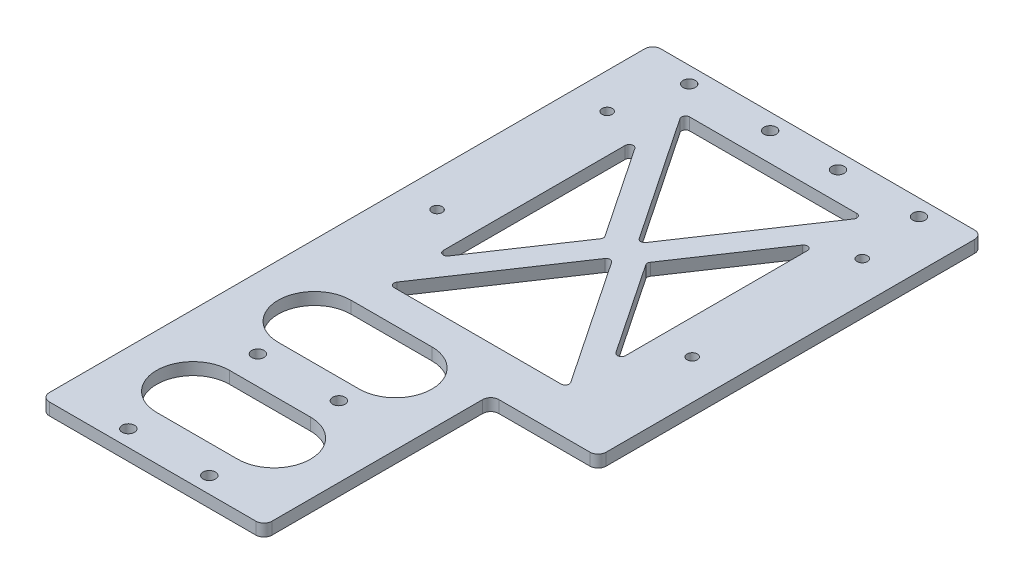
from build123d import *

# Parameters (mm, degrees)
EXTRUDE_1_DEPTH          = 3
SKETCH_2_R               = 1.525
CUT_EXTRUDE_1_DEPTH      = 4
SKETCH_3_R               = 1.275
CUT_EXTRUDE_2_DEPTH      = 4
SKETCH_5_W               = 6.5
SKETCH_5_H               = 95
CUT_EXTRUDE_4_DEPTH      = 4
FILLET_3_R               = 2
CUT_EXTRUDE_5_DEPTH      = 1
CUT_EXTRUDE_5_DEPTH_BACK = 4
FILLET_4_R               = 1
CUT_EXTRUDE_6_DEPTH      = 1
CUT_EXTRUDE_6_DEPTH_BACK = 4


with BuildPart() as part:
    # 草图1 → 凸台-拉伸1 (new body)
    with BuildSketch(Plane(origin=(0, 0, 0), x_dir=(1, 0, 0), z_dir=(0, 1, 0))):
        Polygon((33, -55), (33, 0), (33, 40), (-55, 40), (-55, -111), (0, -111), (0, -55), align=None)
    extrude(amount=EXTRUDE_1_DEPTH)

    # 草图2 → 切除-拉伸1 (cut, through all)
    with BuildSketch(Plane(origin=(0, 3, 0), x_dir=(1, 0, 0), z_dir=(0, 1, 0))):
        with Locations((-37.5, -107)):
            Circle(SKETCH_2_R)
        with Locations((-17.5, -107)):
            Circle(SKETCH_2_R)
        with Locations((-37.5, -75)):
            Circle(SKETCH_2_R)
        with Locations((-17.5, -75)):
            Circle(SKETCH_2_R)
        with Locations((-42, 36)):
            Circle(SKETCH_2_R)
        with Locations((-22, 36)):
            Circle(SKETCH_2_R)
        with Locations((-5.25, 36)):
            Circle(SKETCH_2_R)
        with Locations((14.75, 36)):
            Circle(SKETCH_2_R)
    extrude(amount=-CUT_EXTRUDE_1_DEPTH, mode=Mode.SUBTRACT)

    # 草图3 → 切除-拉伸2 (cut, through all)
    with BuildSketch(Plane(origin=(0, 3, 0), x_dir=(1, 0, 0), z_dir=(0, 1, 0))):
        with Locations((16.75, 20)):
            Circle(SKETCH_3_R)
        with Locations((-46.25, 20)):
            Circle(SKETCH_3_R)
        with Locations((16.75, -22)):
            Circle(SKETCH_3_R)
        with Locations((-46.25, -22)):
            Circle(SKETCH_3_R)
    extrude(amount=-CUT_EXTRUDE_2_DEPTH, mode=Mode.SUBTRACT)

    # 草图5 → 切除-拉伸4 (cut, through all)
    with BuildSketch(Plane(origin=(0, 3, 0), x_dir=(1, 0, 0), z_dir=(0, 1, 0))):
        with Locations((29.75, -7.5)):
            Rectangle(SKETCH_5_W, SKETCH_5_H)
    extrude(amount=-CUT_EXTRUDE_4_DEPTH, mode=Mode.SUBTRACT)

    # 圆角3
    fillet_3_edges = [part.edges().sort_by_distance(p)[0] for p in [
        (0, 1.5, 111),
        (-55, 1.5, 111),
        (-55, 1.5, -40),
        (0, 1.5, 55),
        (26.5, 1.5, 55),
        (26.5, 1.5, -40),
    ]]
    fillet(fillet_3_edges, radius=FILLET_3_R)

    # 草图6 → 切除-拉伸5 (cut, two sides)
    with BuildSketch(Plane(origin=(0, 3, 0), x_dir=(1, 0, 0), z_dir=(0, 1, 0))) as cut_extrude_5_sk:
        Polygon((-36.75, 29), (8.25, 29), (-14.25, -4.5), align=None)
        Polygon((-36.75, 18.238752654), (-36.75, -33.238752654), (-19.462778068, -7.5), align=None)
        Polygon((-9.037221932, -7.5), (8.25, 18.238752654), (8.25, -33.238752654), align=None)
        Polygon((-36.75, -44), (8.25, -44), (-14.25, -10.5), align=None)
    extrude(amount=CUT_EXTRUDE_5_DEPTH, mode=Mode.SUBTRACT)
    extrude(cut_extrude_5_sk.sketch, amount=-CUT_EXTRUDE_5_DEPTH_BACK, mode=Mode.SUBTRACT)

    # 圆角4
    fillet_4_edges = [part.edges().sort_by_distance(p)[0] for p in [
        (-36.75, 1.5, -18.238752654),
        (-19.462778068, 1.5, 7.5),
        (-36.75, 1.5, 33.238752654),
        (8.25, 1.5, 33.238752654),
        (-9.037221932, 1.5, 7.5),
        (8.25, 1.5, -18.238752654),
        (-36.75, 1.5, 44),
        (-14.25, 1.5, 10.5),
        (8.25, 1.5, 44),
        (-14.25, 1.5, 4.5),
        (-36.75, 1.5, -29),
        (8.25, 1.5, -29),
    ]]
    fillet(fillet_4_edges, radius=FILLET_4_R)

    # 草图7 → 切除-拉伸6 (cut, two sides)
    with BuildSketch(Plane(origin=(0, 3, 0), x_dir=(1, 0, 0), z_dir=(0, 1, 0))) as cut_extrude_6_sk:
        with BuildLine():
            Line((-37.5, -52), (-17.5, -52))
            ThreePointArc((-17.5, -52), (-8.5, -61), (-17.5, -70))
            Line((-17.5, -70), (-37.5, -70))
            ThreePointArc((-37.5, -70), (-46.5, -61), (-37.5, -52))
        make_face()
        with BuildLine():
            Line((-37.5, -82), (-17.5, -82))
            ThreePointArc((-17.5, -82), (-8.5, -91), (-17.5, -100))
            Line((-17.5, -100), (-37.5, -100))
            ThreePointArc((-37.5, -100), (-46.5, -91), (-37.5, -82))
        make_face()
    extrude(amount=CUT_EXTRUDE_6_DEPTH, mode=Mode.SUBTRACT)
    extrude(cut_extrude_6_sk.sketch, amount=-CUT_EXTRUDE_6_DEPTH_BACK, mode=Mode.SUBTRACT)


solid = part.part
